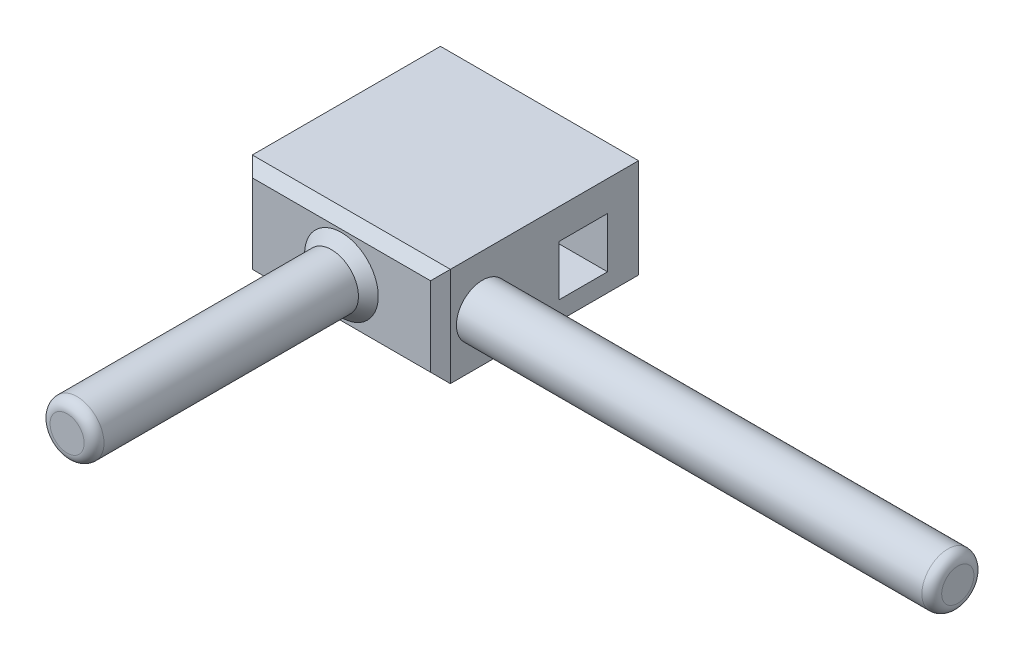
from build123d import *

# Parameters (mm, degrees)
BOSS_EXTRUDE1_DEPTH      = 10
BOSS_EXTRUDE1_DEPTH_BACK = 10
SKETCH1_W                = 20
SKETCH1_H                = 10
SKETCH3_R                = 2.720672102
BOSS_EXTRUDE2_DEPTH      = 27.695455009
SKETCH6_R                = 2.626203493
BOSS_EXTRUDE3_DEPTH      = 48
SKETCH6_5_W              = 4.878057838
SKETCH6_5_H              = 5.100515908
CUT_EXTRUDE2_DEPTH       = 48
FILLET1_R                = 1
CHAMFER1_SIZE            = 1
FILLET5_R                = 1


with BuildPart() as part:
    # Sketch1 → Boss-Extrude1 (new, two sides: drawn at the far end of the back side and taken through both)
    with BuildSketch(Plane.XY.offset(-BOSS_EXTRUDE1_DEPTH_BACK)):
        with Locations((10, 5)):
            Rectangle(SKETCH1_W, SKETCH1_H)
    extrude(amount=BOSS_EXTRUDE1_DEPTH + BOSS_EXTRUDE1_DEPTH_BACK)

    # Sketch3 → Boss-Extrude2 (add)
    with BuildSketch(Plane.XY.offset(10)):
        with Locations((10, 5)):
            Circle(SKETCH3_R)
    extrude(amount=BOSS_EXTRUDE2_DEPTH)

    # Sketch6 → Boss-Extrude3 (add)
    with BuildSketch(Plane(origin=(20, 0, 0), x_dir=(0, 0, -1), z_dir=(1, 0, 0))):
        with Locations((-5.764422097, 4.80674108)):
            Circle(SKETCH6_R)
    extrude(amount=BOSS_EXTRUDE3_DEPTH)

    # Sketch6_5 → Cut-Extrude2 (cut)
    with BuildSketch(Plane(origin=(20, 0, 0), x_dir=(0, 0, -1), z_dir=(1, 0, 0))):
        with Locations((4.426041194, 4.399566895)):
            Rectangle(SKETCH6_5_W, SKETCH6_5_H)
    extrude(amount=-CUT_EXTRUDE2_DEPTH, mode=Mode.SUBTRACT)

    # Fillet1
    fillet1_edges = [part.edges().sort_by_distance(p)[0] for p in [
        (7.279327898, 5, 37.695455009),
    ]]
    fillet(fillet1_edges, radius=FILLET1_R)

    # Chamfer1
    chamfer1_edges = [part.edges().sort_by_distance(p)[0] for p in [
        (10, 10, 10),
        (20, 5, 10),
        (10, 0, 10),
        (0, 5, 10),
        (7.279327898, 5, 10),
    ]]
    chamfer(chamfer1_edges, length=CHAMFER1_SIZE)

    # Fillet5
    fillet5_edges = [part.edges().sort_by_distance(p)[0] for p in [
        (68, 4.80674108, 8.390625589),
    ]]
    fillet(fillet5_edges, radius=FILLET5_R)


solid = part.part
